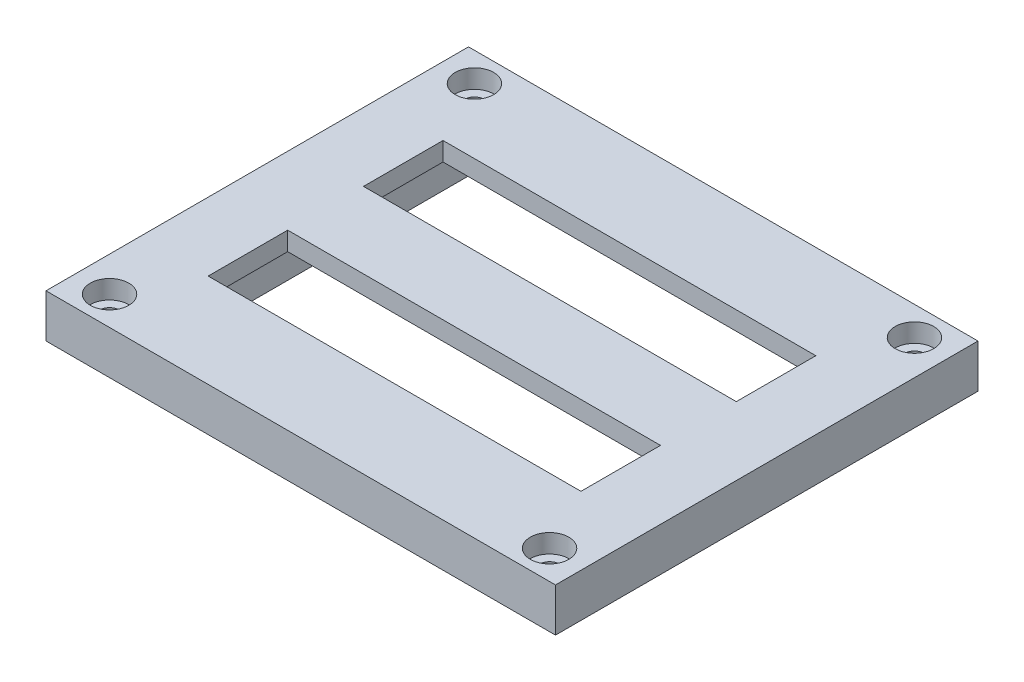
from build123d import *

# Parameters (mm, degrees)
SKETCH1_W             = 76
SKETCH1_H             = 62
BOSS_EXTRUDE1_DEPTH   = 2
SKETCH2_W             = 82
SKETCH2_H             = 68
BOSS_EXTRUDE2_DEPTH   = 8
SKETCH3_W             = 60
SKETCH3_H             = 12.8
CUT_EXTRUDE1_DEPTH    = 11
SKETCH4_R             = 1.6
CUT_EXTRUDE2_DEPTH    = 11
SKETCH5_R             = 3.1
CUT_EXTRUDE3_DEPTH    = 3
SKETCH9_OUTSIDE_W     = 105.4
SKETCH9_OUTSIDE_H     = 91.4
SKETCH9_OUTSIDE_W_2   = 75.6
SKETCH9_OUTSIDE_H_2   = 61.6
CUT_EXTRUDE5_DEPTH    = 3
CUT_EXTRUDE6_DEPTH    = 3
SKETCH11_W            = 66
SKETCH11_H            = 54
CUT_EXTRUDE7_DEPTH    = 7
CHAMFER2_SIZE         = 2
CHAMFER2_SIZE2        = 0.352653961
CHAMFER2_PART_2_SIZE  = 2
CHAMFER2_PART_2_SIZE2 = 0.352653961
CHAMFER3_SIZE         = 1
CHAMFER3_SIZE2        = 1.732050808


with BuildPart() as part:
    # Sketch1 → Boss-Extrude1 (new body)
    with BuildSketch(Plane(origin=(0, 0, 0), x_dir=(1, 0, 0), z_dir=(0, 1, 0))):
        Rectangle(SKETCH1_W, SKETCH1_H)
    extrude(amount=BOSS_EXTRUDE1_DEPTH)

    # Sketch2 → Boss-Extrude2 (add)
    with BuildSketch(Plane(origin=(0, 2, 0), x_dir=(1, 0, 0), z_dir=(0, 1, 0))):
        Rectangle(SKETCH2_W, SKETCH2_H)
    extrude(amount=BOSS_EXTRUDE2_DEPTH)

    # Sketch3 → Cut-Extrude1 (cut, through all)
    with BuildSketch(Plane.XZ):
        with Locations((0, -12.5)):
            Rectangle(SKETCH3_W, SKETCH3_H)
        with Locations((0, 12.5)):
            Rectangle(SKETCH3_W, SKETCH3_H)
    extrude(amount=-CUT_EXTRUDE1_DEPTH, mode=Mode.SUBTRACT)

    # Sketch4 → Cut-Extrude2 (cut, through all)
    with BuildSketch(Plane(origin=(0, 10, 0), x_dir=(1, 0, 0), z_dir=(0, 1, 0))):
        with Locations(Location((-35.408866178, 29.363450001, 0), (0, 0, 270))):  # turned: the seam where the file's is
            Circle(SKETCH4_R)
        with Locations(Location((35.408866178, 29.363450001, 0), (0, 0, 270))):  # turned: the seam where the file's is
            Circle(SKETCH4_R)
        with Locations(Location((35.408866178, -29.363450001, 0), (0, 0, 270))):  # turned: the seam where the file's is
            Circle(SKETCH4_R)
        with Locations(Location((-35.408866178, -29.363450001, 0), (0, 0, 270))):  # turned: the seam where the file's is
            Circle(SKETCH4_R)
    extrude(amount=-CUT_EXTRUDE2_DEPTH, mode=Mode.SUBTRACT)

    # Sketch5 → Cut-Extrude3 (cut)
    with BuildSketch(Plane(origin=(0, 10, 0), x_dir=(1, 0, 0), z_dir=(0, 1, 0))):
        with Locations(Location((-35.408866178, 29.363450001, 0), (0, 0, 270))):  # turned: the seam where the file's is
            Circle(SKETCH5_R)
        with Locations(Location((35.408866178, 29.363450001, 0), (0, 0, 270))):  # turned: the seam where the file's is
            Circle(SKETCH5_R)
        with Locations(Location((35.408866178, -29.363450001, 0), (0, 0, 270))):  # turned: the seam where the file's is
            Circle(SKETCH5_R)
        with Locations(Location((-35.408866178, -29.363450001, 0), (0, 0, 270))):  # turned: the seam where the file's is
            Circle(SKETCH5_R)
    extrude(amount=-CUT_EXTRUDE3_DEPTH, mode=Mode.SUBTRACT)

    # Sketch9 outside → Cut-Extrude5 (cut)
    with BuildSketch(Plane.XZ):
        Rectangle(SKETCH9_OUTSIDE_W, SKETCH9_OUTSIDE_H)
        Rectangle(SKETCH9_OUTSIDE_W_2, SKETCH9_OUTSIDE_H_2, mode=Mode.SUBTRACT)
    extrude(amount=-CUT_EXTRUDE5_DEPTH, mode=Mode.SUBTRACT)

    # Sketch10 → Cut-Extrude6 (cut)
    with BuildSketch(Plane.XZ):
        Polygon((-37.8, -30.8), (-31.8, -30.8), (-37.8, -24.8), align=None)
        Polygon((-37.8, 24.8), (-37.8, 30.8), (-31.8, 30.8), align=None)
        Polygon((37.8, 30.8), (37.8, 24.8), (31.8, 30.8), align=None)
        Polygon((37.8, -30.8), (31.8, -30.8), (37.8, -24.8), align=None)
    extrude(amount=-CUT_EXTRUDE6_DEPTH, mode=Mode.SUBTRACT)

    # Sketch11 → Cut-Extrude7 (cut)
    with BuildSketch(Plane.XZ):
        Rectangle(SKETCH11_W, SKETCH11_H)
    extrude(amount=-CUT_EXTRUDE7_DEPTH, mode=Mode.SUBTRACT)

    # Chamfer2
    chamfer2_edges = [part.edges().sort_by_distance(p)[0] for p in [
        (37.8, 0, 0),
    ]]
    chamfer2_side = [part.faces().sort_by_distance(p)[0] for p in [
        (37.8, 1.5, 0),
    ]]
    chamfer(chamfer2_edges, length=CHAMFER2_SIZE, length2=CHAMFER2_SIZE2, reference=chamfer2_side[0])

    # Chamfer2 part 2
    chamfer2_part_2_edges = [part.edges().sort_by_distance(p)[0] for p in [
        (-37.8, 0, 0),
    ]]
    chamfer2_part_2_side = [part.faces().sort_by_distance(p)[0] for p in [
        (-37.8, 1.5, 0),
    ]]
    chamfer(chamfer2_part_2_edges, length=CHAMFER2_PART_2_SIZE, length2=CHAMFER2_PART_2_SIZE2, reference=chamfer2_part_2_side[0])

    # Chamfer3
    chamfer3_edges = [part.edges().sort_by_distance(p)[0] for p in [
        (0, 0, -30.8),
        (0, 0, 30.8),
    ]]
    chamfer3_side = [part.faces().sort_by_distance(p)[0] for p in [
        (-35.357643735, 0, 25.870950059),
    ]]
    chamfer(chamfer3_edges, length=CHAMFER3_SIZE, length2=CHAMFER3_SIZE2, reference=chamfer3_side[0])


solid = part.part
